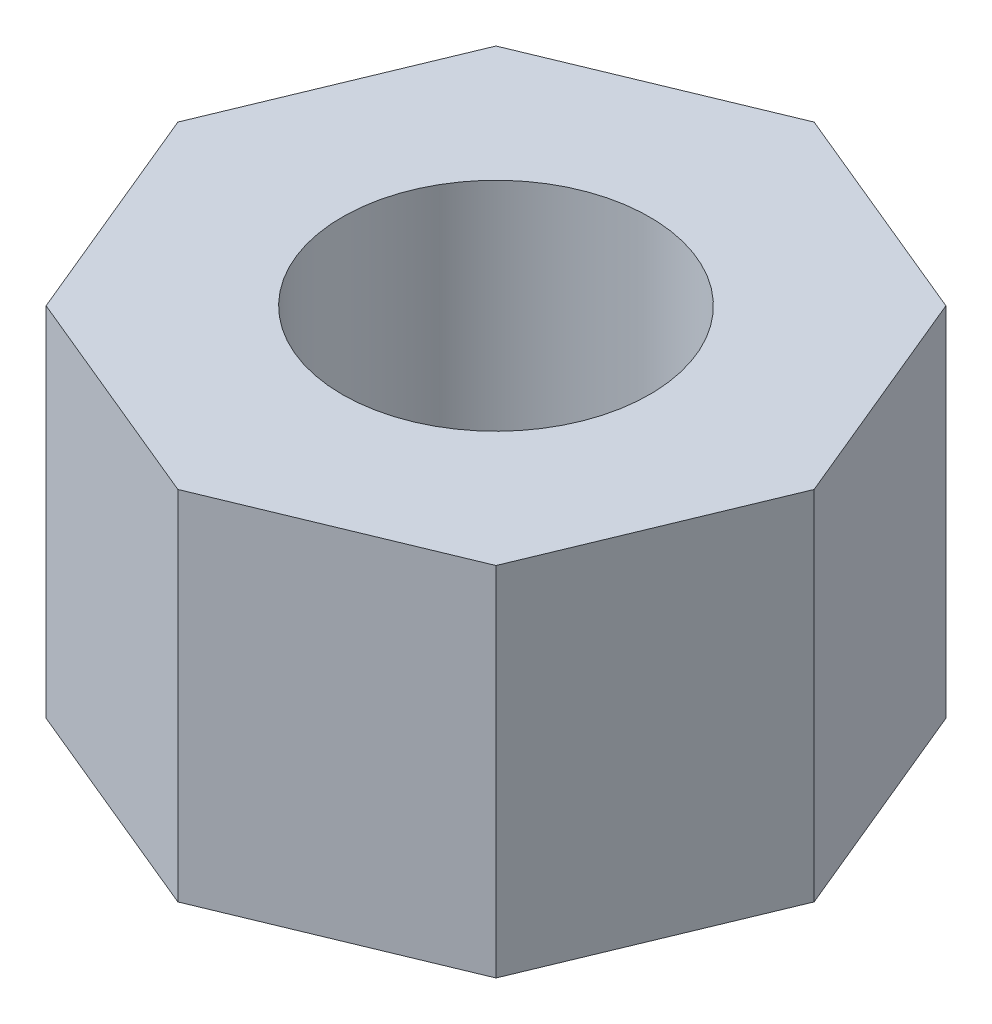
from build123d import *

# Parameters (mm, degrees)
SKETCH1_R           = 3.4
BOSS_EXTRUDE1_DEPTH = 7.9


with BuildPart() as part:
    # Sketch1 → Boss-Extrude1 (new body)
    with BuildSketch(Plane(origin=(0, 0, 0), x_dir=(1, 0, 0), z_dir=(0, 1, 0))):
        Polygon((0, -7.035549302), (4.974884621, -4.974884621), (7.035549302, 0), (4.974884621, 4.974884621), (0, 7.035549302), (-4.974884621, 4.974884621), (-7.035549302, 0), (-4.974884621, -4.974884621), align=None)
        Circle(SKETCH1_R, mode=Mode.SUBTRACT)
    extrude(amount=BOSS_EXTRUDE1_DEPTH)


solid = part.part
